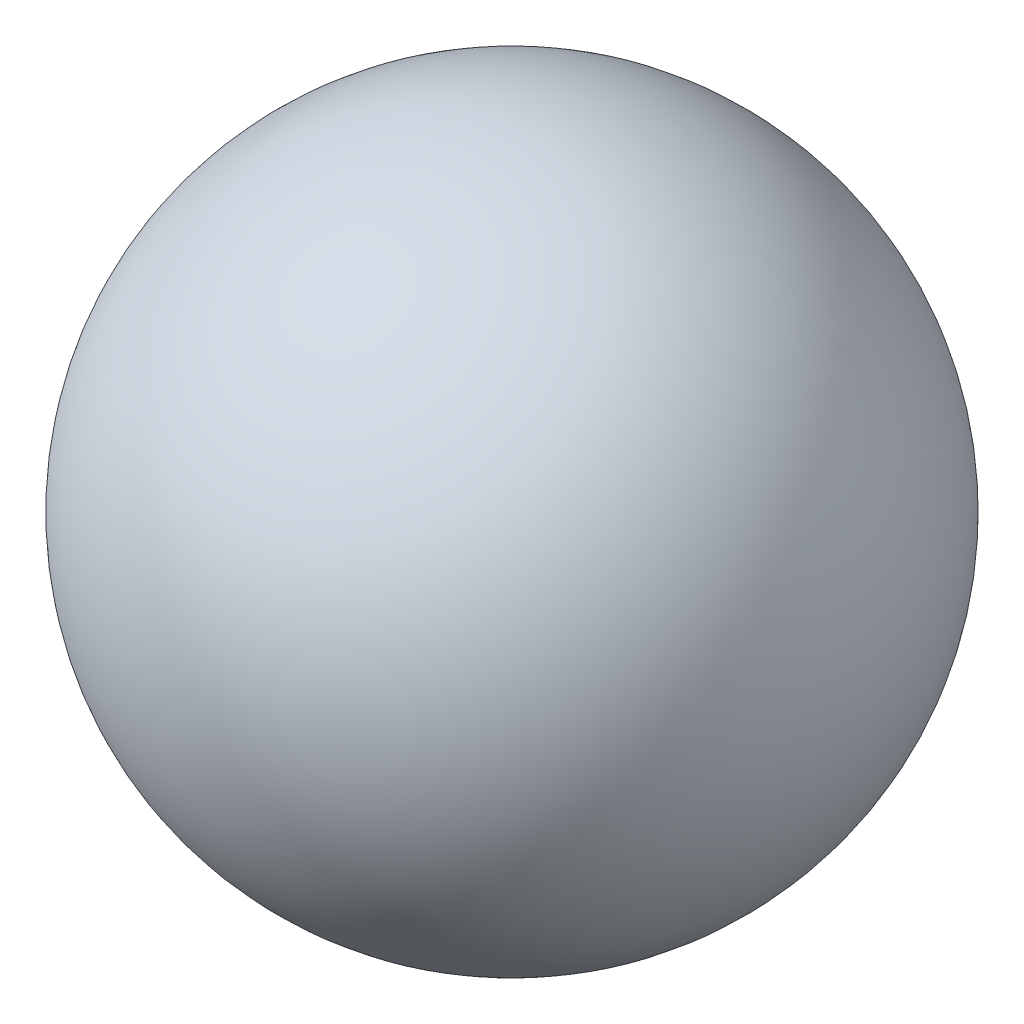
from build123d import *


with BuildPart() as part:
    # Эскиз1 → Повернуть1 (revolve)
    with BuildSketch(Plane.XY):
        with BuildLine():
            Line((0, 7), (0, -7))
            ThreePointArc((0, -7), (-7, 0), (0, 7))
        make_face()
    revolve(axis=Axis((0, 0, 0), (0, 1, 0)))


solid = part.part
